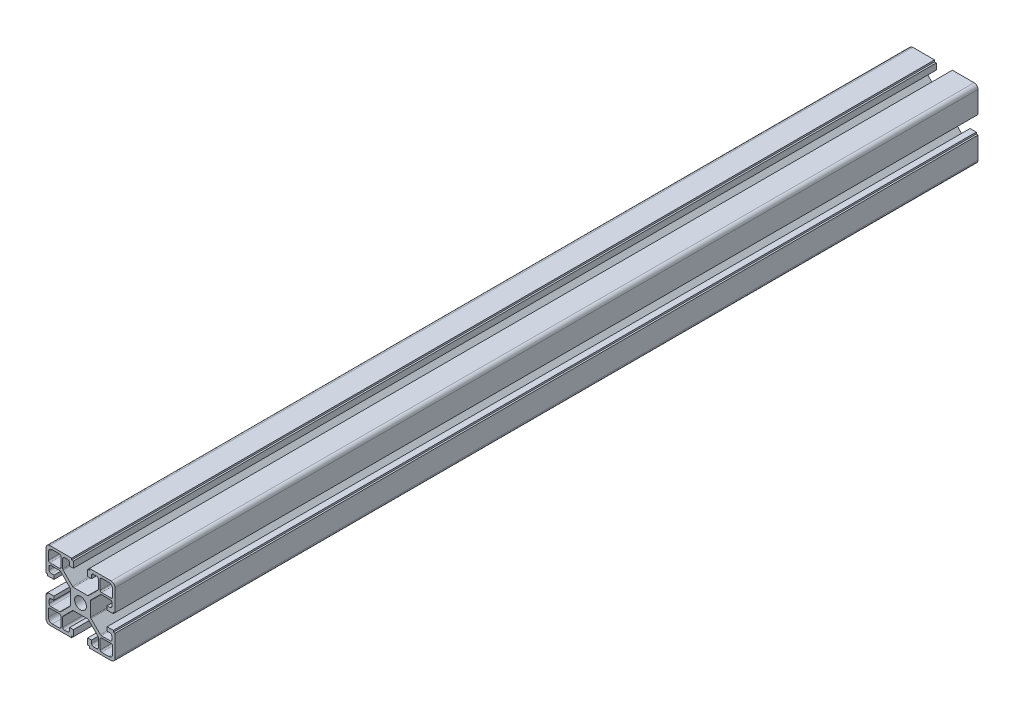
from build123d import *

# Parameters (mm, degrees)
SKETCH1_R           = 3.4
BOSS_EXTRUDE1_DEPTH = 500


with BuildPart() as part:
    # Sketch1 → Boss-Extrude1 (new body)
    with BuildSketch(Plane.XY):
        with BuildLine():
            Line((20, 17.75), (20, 5.15))
            Line((20, 5.15), (19, 5.15))
            Line((19, 5.15), (19, 4.15))
            Line((19, 4.15), (15.4, 4.15))
            Line((15.4, 4.15), (15.4, 6.35))
            Line((15.4, 6.35), (16.95, 6.35))
            ThreePointArc((16.95, 6.35), (17.833883476, 6.716116524), (18.2, 7.6))
            Line((18.2, 7.6), (18.2, 9.3))
            ThreePointArc((18.2, 9.3), (17.907106781, 10.007106781), (17.2, 10.3))
            Line((17.2, 10.3), (12.03669957, 10.3))
            ThreePointArc((12.03669957, 10.3), (11.73040037, 10.239040459), (11.470780817, 10.065452001))
            Line((11.470780817, 10.065452001), (6.084081247, 4.674305984))
            ThreePointArc((6.084081247, 4.674305984), (5.910833239, 4.414848262), (5.85, 4.108853983))
            Line((5.85, 4.108853983), (5.85, -4.108853983))
            ThreePointArc((5.85, -4.108853983), (5.910833239, -4.414848262), (6.084081247, -4.674305984))
            Line((6.084081247, -4.674305984), (11.470780817, -10.065452001))
            ThreePointArc((11.470780817, -10.065452001), (11.73040037, -10.239040459), (12.03669957, -10.3))
            Line((12.03669957, -10.3), (17.2, -10.3))
            ThreePointArc((17.2, -10.3), (17.907106781, -10.007106781), (18.2, -9.3))
            Line((18.2, -9.3), (18.2, -7.6))
            ThreePointArc((18.2, -7.6), (17.833883476, -6.716116524), (16.95, -6.35))
            Line((16.95, -6.35), (15.4, -6.35))
            Line((15.4, -6.35), (15.4, -4.15))
            Line((15.4, -4.15), (19, -4.15))
            Line((19, -4.15), (19, -5.15))
            Line((19, -5.15), (20, -5.15))
            Line((20, -5.15), (20, -17.75))
            ThreePointArc((20, -17.75), (19.340990258, -19.340990258), (17.75, -20))
            Line((17.75, -20), (5.15, -20))
            Line((5.15, -20), (5.15, -19))
            Line((5.15, -19), (4.15, -19))
            Line((4.15, -19), (4.15, -15.4))
            Line((4.15, -15.4), (6.35, -15.4))
            Line((6.35, -15.4), (6.35, -16.95))
            ThreePointArc((6.35, -16.95), (6.716116524, -17.833883476), (7.6, -18.2))
            Line((7.6, -18.2), (9.3, -18.2))
            ThreePointArc((9.3, -18.2), (10.007106781, -17.907106781), (10.3, -17.2))
            Line((10.3, -17.2), (10.3, -12.054477022))
            ThreePointArc((10.3, -12.054477022), (10.239166761, -11.748482743), (10.065918753, -11.489025021))
            Line((10.065918753, -11.489025021), (4.665899173, -6.084547999))
            ThreePointArc((4.665899173, -6.084547999), (4.406279619, -5.910959541), (4.09998042, -5.85))
            Line((4.09998042, -5.85), (-4.09998042, -5.85))
            ThreePointArc((-4.09998042, -5.85), (-4.406279619, -5.910959541), (-4.665899173, -6.084547999))
            Line((-4.665899173, -6.084547999), (-10.065918753, -11.489025021))
            ThreePointArc((-10.065918753, -11.489025021), (-10.239166761, -11.748482743), (-10.3, -12.054477022))
            Line((-10.3, -12.054477022), (-10.3, -17.2))
            ThreePointArc((-10.3, -17.2), (-10.007106781, -17.907106781), (-9.3, -18.2))
            Line((-9.3, -18.2), (-7.6, -18.2))
            ThreePointArc((-7.6, -18.2), (-6.716116524, -17.833883476), (-6.35, -16.95))
            Line((-6.35, -16.95), (-6.35, -15.4))
            Line((-6.35, -15.4), (-4.15, -15.4))
            Line((-4.15, -15.4), (-4.15, -19))
            Line((-4.15, -19), (-5.15, -19))
            Line((-5.15, -19), (-5.15, -20))
            Line((-5.15, -20), (-17.75, -20))
            ThreePointArc((-17.75, -20), (-19.340990258, -19.340990258), (-20, -17.75))
            Line((-20, -17.75), (-20, -5.15))
            Line((-20, -5.15), (-19, -5.15))
            Line((-19, -5.15), (-19, -4.15))
            Line((-19, -4.15), (-15.4, -4.15))
            Line((-15.4, -4.15), (-15.4, -6.35))
            Line((-15.4, -6.35), (-16.95, -6.35))
            ThreePointArc((-16.95, -6.35), (-17.833883476, -6.716116524), (-18.2, -7.6))
            Line((-18.2, -7.6), (-18.2, -9.3))
            ThreePointArc((-18.2, -9.3), (-17.907106781, -10.007106781), (-17.2, -10.3))
            Line((-17.2, -10.3), (-12.03669957, -10.3))
            ThreePointArc((-12.03669957, -10.3), (-11.73040037, -10.239040459), (-11.470780817, -10.065452001))
            Line((-11.470780817, -10.065452001), (-6.084081247, -4.674305984))
            ThreePointArc((-6.084081247, -4.674305984), (-5.910833239, -4.414848262), (-5.85, -4.108853983))
            Line((-5.85, -4.108853983), (-5.85, 4.108853983))
            ThreePointArc((-5.85, 4.108853983), (-5.910833239, 4.414848262), (-6.084081247, 4.674305984))
            Line((-6.084081247, 4.674305984), (-11.470780817, 10.065452001))
            ThreePointArc((-11.470780817, 10.065452001), (-11.73040037, 10.239040459), (-12.03669957, 10.3))
            Line((-12.03669957, 10.3), (-17.2, 10.3))
            ThreePointArc((-17.2, 10.3), (-17.907106781, 10.007106781), (-18.2, 9.3))
            Line((-18.2, 9.3), (-18.2, 7.6))
            ThreePointArc((-18.2, 7.6), (-17.833883476, 6.716116524), (-16.95, 6.35))
            Line((-16.95, 6.35), (-15.4, 6.35))
            Line((-15.4, 6.35), (-15.4, 4.15))
            Line((-15.4, 4.15), (-19, 4.15))
            Line((-19, 4.15), (-19, 5.15))
            Line((-19, 5.15), (-20, 5.15))
            Line((-20, 5.15), (-20, 17.75))
            ThreePointArc((-20, 17.75), (-19.340990258, 19.340990258), (-17.75, 20))
            Line((-17.75, 20), (-5.15, 20))
            Line((-5.15, 20), (-5.15, 19))
            Line((-5.15, 19), (-4.15, 19))
            Line((-4.15, 19), (-4.15, 15.4))
            Line((-4.15, 15.4), (-6.35, 15.4))
            Line((-6.35, 15.4), (-6.35, 16.95))
            ThreePointArc((-6.35, 16.95), (-6.716116524, 17.833883476), (-7.6, 18.2))
            Line((-7.6, 18.2), (-9.3, 18.2))
            ThreePointArc((-9.3, 18.2), (-10.007106781, 17.907106781), (-10.3, 17.2))
            Line((-10.3, 17.2), (-10.3, 12.054477022))
            ThreePointArc((-10.3, 12.054477022), (-10.239166761, 11.748482743), (-10.065918753, 11.489025021))
            Line((-10.065918753, 11.489025021), (-4.665899173, 6.084547999))
            ThreePointArc((-4.665899173, 6.084547999), (-4.406279619, 5.910959541), (-4.09998042, 5.85))
            Line((-4.09998042, 5.85), (4.09998042, 5.85))
            ThreePointArc((4.09998042, 5.85), (4.406279619, 5.910959541), (4.665899173, 6.084547999))
            Line((4.665899173, 6.084547999), (10.065918753, 11.489025021))
            ThreePointArc((10.065918753, 11.489025021), (10.239166761, 11.748482743), (10.3, 12.054477022))
            Line((10.3, 12.054477022), (10.3, 17.2))
            ThreePointArc((10.3, 17.2), (10.007106781, 17.907106781), (9.3, 18.2))
            Line((9.3, 18.2), (7.6, 18.2))
            ThreePointArc((7.6, 18.2), (6.716116524, 17.833883476), (6.35, 16.95))
            Line((6.35, 16.95), (6.35, 15.4))
            Line((6.35, 15.4), (4.15, 15.4))
            Line((4.15, 15.4), (4.15, 19))
            Line((4.15, 19), (5.15, 19))
            Line((5.15, 19), (5.15, 20))
            Line((5.15, 20), (17.75, 20))
            ThreePointArc((17.75, 20), (19.340990258, 19.340990258), (20, 17.75))
        make_face()
        Circle(SKETCH1_R, mode=Mode.SUBTRACT)
        with BuildLine():
            Line((18.6, 16.35), (18.6, 12.2))
            ThreePointArc((18.6, 12.2), (18.365685425, 11.634314575), (17.8, 11.4))
            Line((17.8, 11.4), (12.2, 11.4))
            ThreePointArc((12.2, 11.4), (11.634314575, 11.634314575), (11.4, 12.2))
            Line((11.4, 12.2), (11.4, 17.8))
            ThreePointArc((11.4, 17.8), (11.634314575, 18.365685425), (12.2, 18.6))
            Line((12.2, 18.6), (16.35, 18.6))
            ThreePointArc((16.35, 18.6), (17.940990258, 17.940990258), (18.6, 16.35))
        make_face(mode=Mode.SUBTRACT)
        with BuildLine():
            Line((-12.2, 18.6), (-16.35, 18.6))
            ThreePointArc((-16.35, 18.6), (-17.940990258, 17.940990258), (-18.6, 16.35))
            Line((-18.6, 16.35), (-18.6, 12.2))
            ThreePointArc((-18.6, 12.2), (-18.365685425, 11.634314575), (-17.8, 11.4))
            Line((-17.8, 11.4), (-12.2, 11.4))
            ThreePointArc((-12.2, 11.4), (-11.634314575, 11.634314575), (-11.4, 12.2))
            Line((-11.4, 12.2), (-11.4, 17.8))
            ThreePointArc((-11.4, 17.8), (-11.634314575, 18.365685425), (-12.2, 18.6))
        make_face(mode=Mode.SUBTRACT)
        with BuildLine():
            Line((-18.6, -16.35), (-18.6, -12.2))
            ThreePointArc((-18.6, -12.2), (-18.365685425, -11.634314575), (-17.8, -11.4))
            Line((-17.8, -11.4), (-12.2, -11.4))
            ThreePointArc((-12.2, -11.4), (-11.634314575, -11.634314575), (-11.4, -12.2))
            Line((-11.4, -12.2), (-11.4, -17.8))
            ThreePointArc((-11.4, -17.8), (-11.634314575, -18.365685425), (-12.2, -18.6))
            Line((-12.2, -18.6), (-16.35, -18.6))
            ThreePointArc((-16.35, -18.6), (-17.940990258, -17.940990258), (-18.6, -16.35))
        make_face(mode=Mode.SUBTRACT)
        with BuildLine():
            Line((12.2, -18.6), (16.35, -18.6))
            ThreePointArc((16.35, -18.6), (17.940990258, -17.940990258), (18.6, -16.35))
            Line((18.6, -16.35), (18.6, -12.2))
            ThreePointArc((18.6, -12.2), (18.365685425, -11.634314575), (17.8, -11.4))
            Line((17.8, -11.4), (12.2, -11.4))
            ThreePointArc((12.2, -11.4), (11.634314575, -11.634314575), (11.4, -12.2))
            Line((11.4, -12.2), (11.4, -17.8))
            ThreePointArc((11.4, -17.8), (11.634314575, -18.365685425), (12.2, -18.6))
        make_face(mode=Mode.SUBTRACT)
    extrude(amount=BOSS_EXTRUDE1_DEPTH)


solid = part.part
